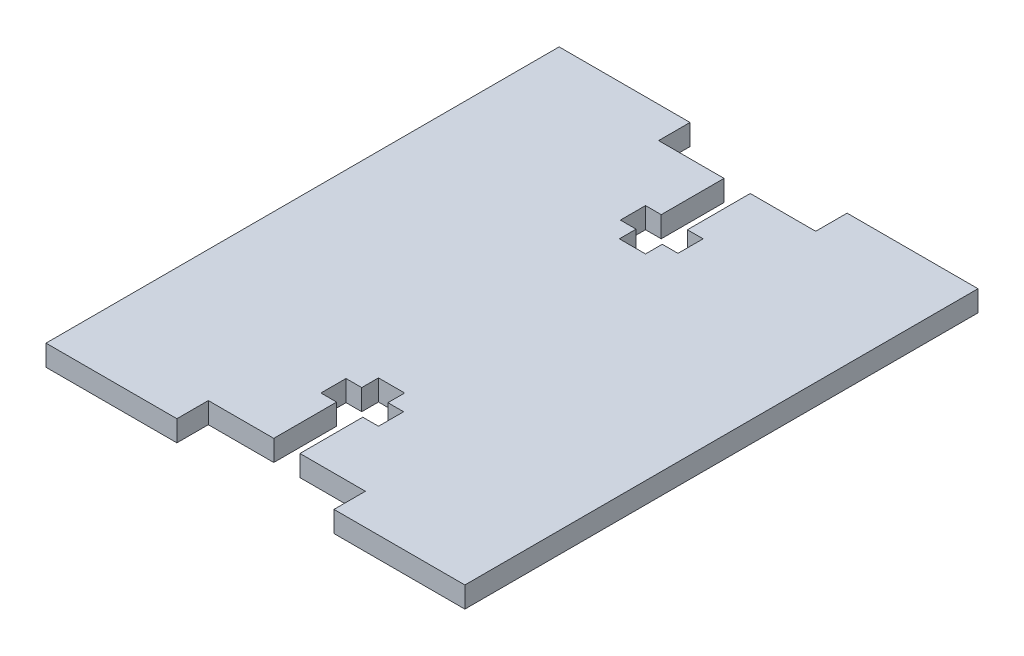
from build123d import *

# Parameters (mm, degrees)
SCHIZZO1_W                   = 40
SCHIZZO1_H                   = 49
ESTRUSIONE_ESTRUSIONE2_DEPTH = 2
SCHIZZO2_W                   = 15
SCHIZZO2_H                   = 3
TAGLIO_ESTRUSIONE1_DEPTH     = 3
TAGLIO_ESTRUSIONE3_DEPTH     = 3


with BuildPart() as part:
    # Schizzo1 → Estrusione-Estrusione2 (new body)
    with BuildSketch(Plane(origin=(0, 0, 0), x_dir=(1, 0, 0), z_dir=(0, 1, 0))):
        with Locations((-34.56494914, -3.781075862)):
            Rectangle(SCHIZZO1_W, SCHIZZO1_H)
    extrude(amount=-ESTRUSIONE_ESTRUSIONE2_DEPTH)

    # Schizzo2 → Taglio-Estrusione1 (cut, through all)
    with BuildSketch(Plane(origin=(0, 0, 0), x_dir=(1, 0, 0), z_dir=(0, 1, 0))):
        with Locations((-34.56494914, -26.781075862)):
            Rectangle(SCHIZZO2_W, SCHIZZO2_H)
        with Locations((-34.56494914, 19.218924138)):
            Rectangle(SCHIZZO2_W, SCHIZZO2_H)
    extrude(amount=-TAGLIO_ESTRUSIONE1_DEPTH, mode=Mode.SUBTRACT)

    # Schizzo3 → Taglio-Estrusione3 (cut, through all)
    with BuildSketch(Plane(origin=(0, 0, 0), x_dir=(1, 0, 0), z_dir=(0, 1, 0))):
        Polygon((-35.81494914, -25.281075862), (-33.31494914, -25.281075862), (-33.31494914, -19.281075862), (-31.81494914, -19.281075862), (-31.81494914, -16.881075862), (-33.31494914, -16.881075862), (-33.31494914, -15.281075862), (-35.81494914, -15.281075862), (-35.81494914, -16.881075862), (-37.31494914, -16.881075862), (-37.31494914, -19.281075862), (-35.81494914, -19.281075862), align=None)
        Polygon((-35.81494914, 7.718924138), (-33.31494914, 7.718924138), (-33.31494914, 9.318924138), (-31.81494914, 9.318924138), (-31.81494914, 11.718924138), (-33.31494914, 11.718924138), (-33.31494914, 17.718924138), (-35.81494914, 17.718924138), (-35.81494914, 11.718924138), (-37.31494914, 11.718924138), (-37.31494914, 9.318924138), (-35.81494914, 9.318924138), align=None)
    extrude(amount=-TAGLIO_ESTRUSIONE3_DEPTH, mode=Mode.SUBTRACT)


solid = part.part
